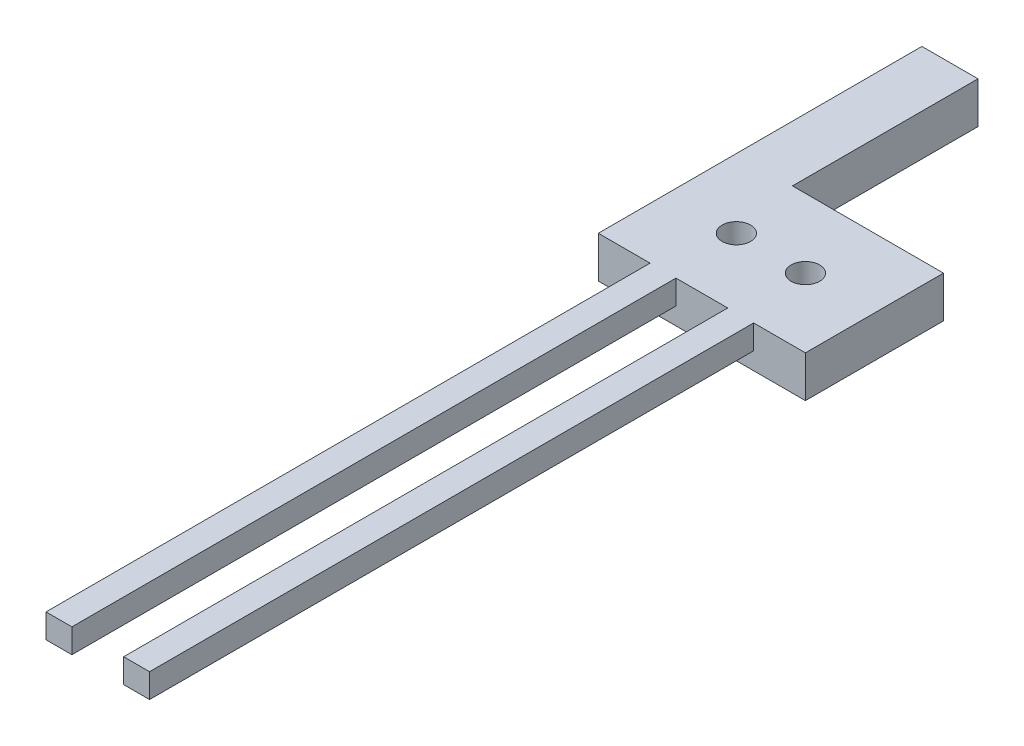
from build123d import *

# Parameters (mm, degrees)
SKETCH1_W           = 24
SKETCH1_H           = 16
SKETCH1_R           = 1.65
BOSS_EXTRUDE1_DEPTH = 4.8
SKETCH2_W           = 3
SKETCH2_H           = 2.8
BOSS_EXTRUDE2_DEPTH = 70
SKETCH4_W           = 6.5
SKETCH4_H           = 21.5
BOSS_EXTRUDE3_DEPTH = 4.8


with BuildPart() as part:
    # Sketch1 → Boss-Extrude1 (new body)
    with BuildSketch(Plane.XZ):
        with Locations((12, -8)):
            Rectangle(SKETCH1_W, SKETCH1_H)
        with Locations((8, -8)):
            Circle(SKETCH1_R, mode=Mode.SUBTRACT)
        with Locations((16, -8)):
            Circle(SKETCH1_R, mode=Mode.SUBTRACT)
    extrude(amount=BOSS_EXTRUDE1_DEPTH)

    # Sketch2 → Boss-Extrude2 (add)
    with BuildSketch(Plane.XY):
        with Locations((7.5, -1.4)):
            Rectangle(SKETCH2_W, SKETCH2_H)
        with Locations((16.5, -1.4)):
            Rectangle(SKETCH2_W, SKETCH2_H)
    extrude(amount=BOSS_EXTRUDE2_DEPTH)

    # Sketch4 → Boss-Extrude3 (add)
    with BuildSketch(Plane(origin=(0, 0, 0), x_dir=(1, 0, 0), z_dir=(0, 1, 0))):
        with Locations((3.25, 26.75)):
            Rectangle(SKETCH4_W, SKETCH4_H)
    extrude(amount=-BOSS_EXTRUDE3_DEPTH)


solid = part.part
